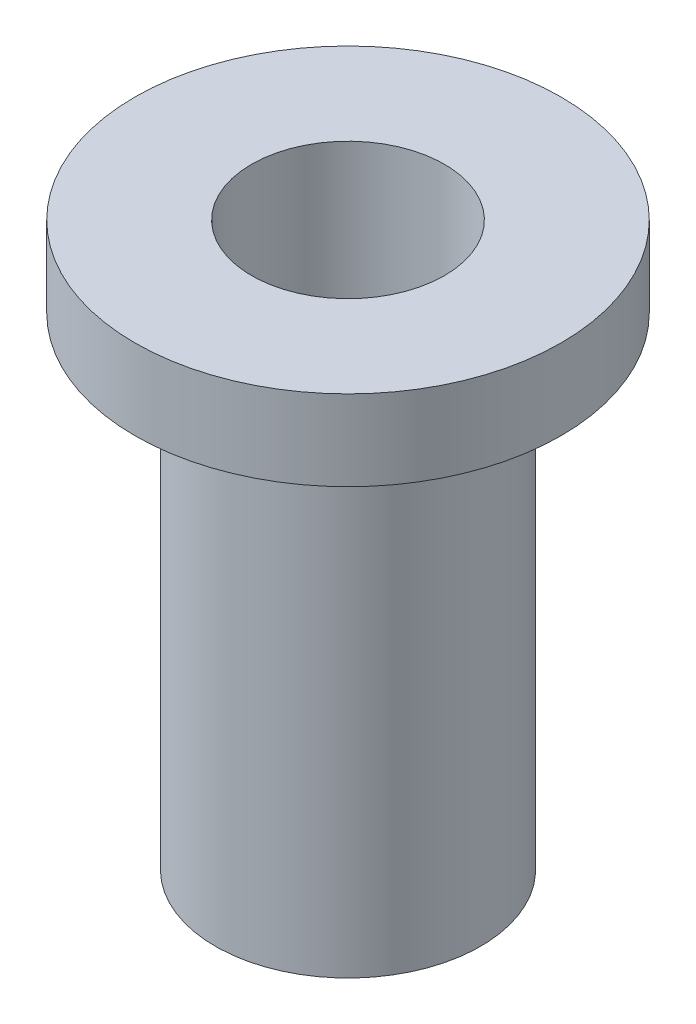
from build123d import *

# Parameters (mm, degrees)
SKETCH3_R          = 1.2
CUT_EXTRUDE1_DEPTH = 5.8


with BuildPart() as part:
    # Sketch2 → Revolve2 (revolve)
    with BuildSketch(Plane.XY):
        Polygon((-1.65, 0), (-1.65, -6), (0, -6), (0, 1), (-2.65, 1), (-2.65, 0), align=None)
    revolve(axis=Axis((0, 2, 0), (0, -1, 0)))

    # Sketch3 → Cut-Extrude1 (cut)
    with BuildSketch(Plane(origin=(0, 1, 0), x_dir=(1, 0, 0), z_dir=(0, 1, 0))):
        Circle(SKETCH3_R)
    extrude(amount=-CUT_EXTRUDE1_DEPTH, mode=Mode.SUBTRACT)


solid = part.part
